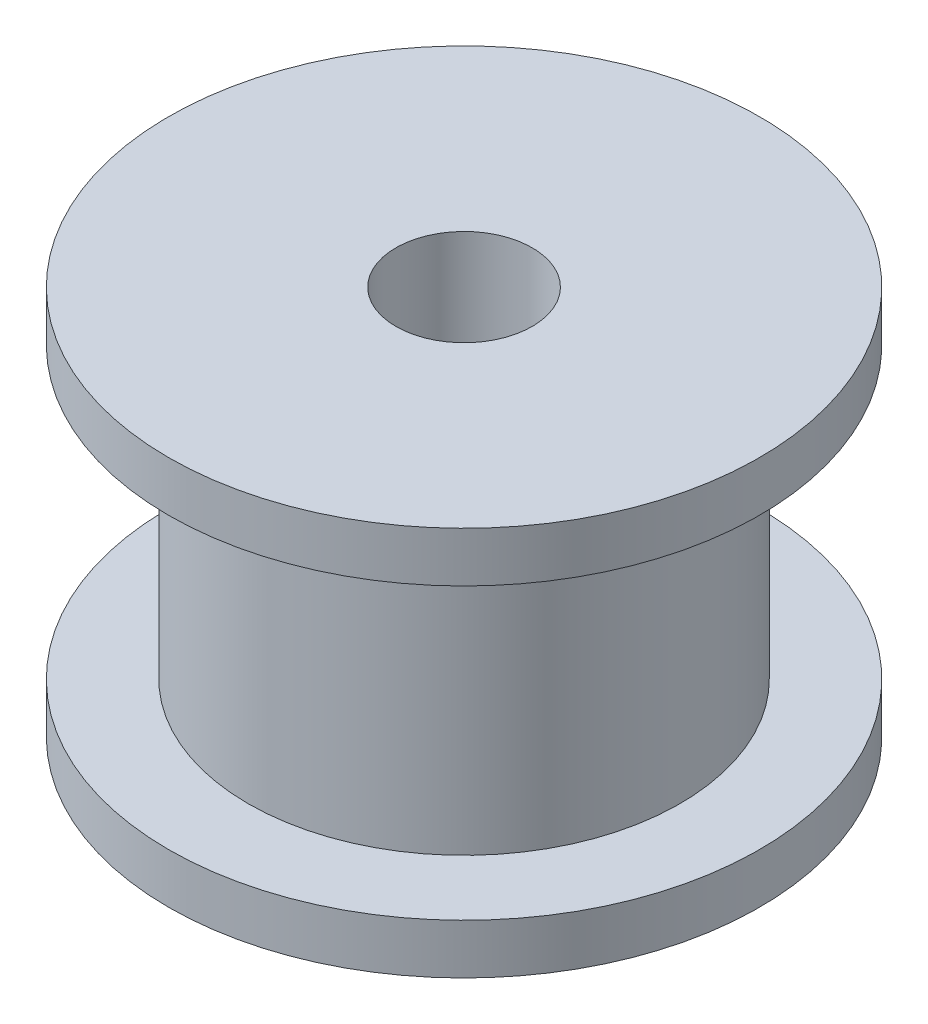
from build123d import *

# Parameters (mm, degrees)
SKETCH1_R           = 6.5
BOSS_EXTRUDE1_DEPTH = 1.1
SKETCH2_R           = 4.75
BOSS_EXTRUDE2_DEPTH = 6.37
SKETCH3_R           = 6.5
BOSS_EXTRUDE3_DEPTH = 1.1
SKETCH4_R           = 1.5
CUT_EXTRUDE1_DEPTH  = 9.57


with BuildPart() as part:
    # Sketch1 → Boss-Extrude1 (new body)
    with BuildSketch(Plane(origin=(0, 0, 0), x_dir=(1, 0, 0), z_dir=(0, 1, 0))):
        Circle(SKETCH1_R)
    extrude(amount=BOSS_EXTRUDE1_DEPTH)

    # Sketch2 → Boss-Extrude2 (add)
    with BuildSketch(Plane(origin=(0, 1.1, 0), x_dir=(1, 0, 0), z_dir=(0, 1, 0))):
        Circle(SKETCH2_R)
    extrude(amount=BOSS_EXTRUDE2_DEPTH)

    # Sketch3 → Boss-Extrude3 (add)
    with BuildSketch(Plane(origin=(0, 7.47, 0), x_dir=(1, 0, 0), z_dir=(0, 1, 0))):
        Circle(SKETCH3_R)
    extrude(amount=BOSS_EXTRUDE3_DEPTH)

    # Sketch4 → Cut-Extrude1 (cut, through all)
    with BuildSketch(Plane(origin=(0, 8.57, 0), x_dir=(1, 0, 0), z_dir=(0, 1, 0))):
        Circle(SKETCH4_R)
    extrude(amount=-CUT_EXTRUDE1_DEPTH, mode=Mode.SUBTRACT)


solid = part.part
